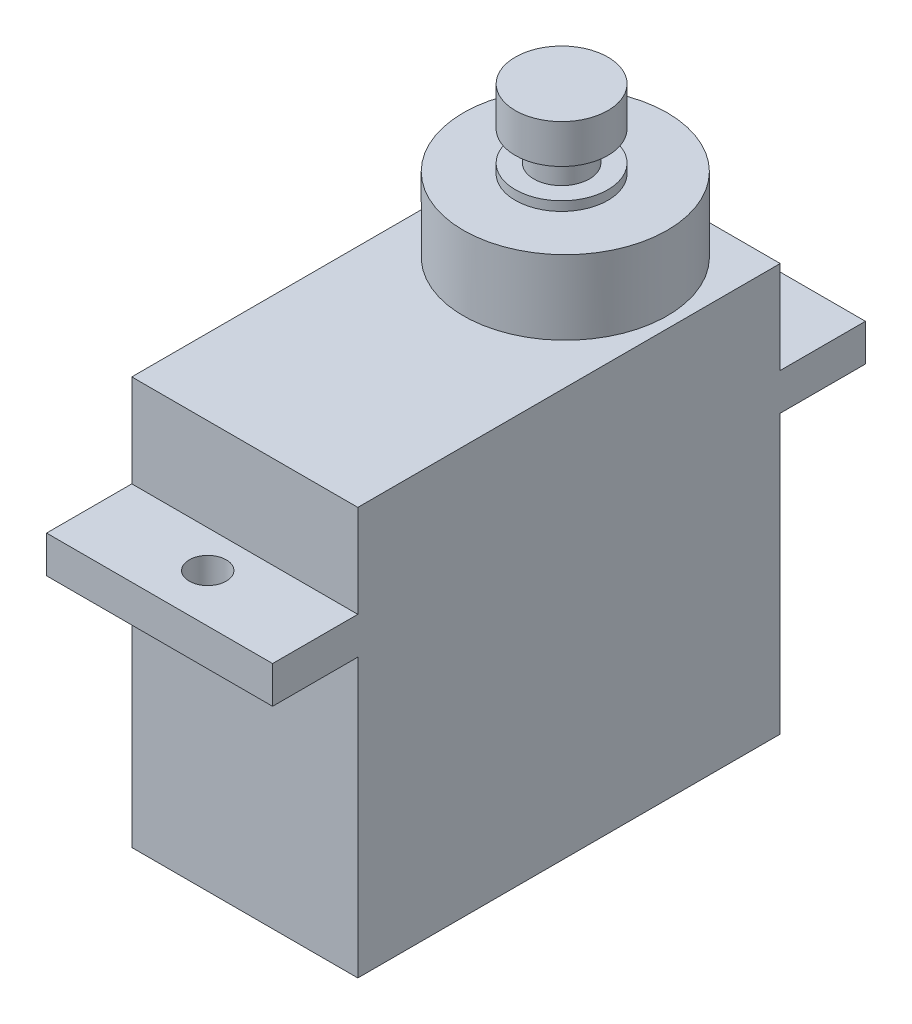
from build123d import *

# Parameters (mm, degrees)
SKETCH2_W           = 12.2
SKETCH2_H           = 22.8
BOSS_EXTRUDE1_DEPTH = 22
SKETCH3_W           = 12.2
SKETCH3_H           = 4.6
SKETCH3_R           = 1
BOSS_EXTRUDE2_DEPTH = 2
SKETCH4_R           = 5.5
BOSS_EXTRUDE3_DEPTH = 4
SKETCH5_R           = 2.5
BOSS_EXTRUDE4_DEPTH = 4.2
SKETCH6_W           = 1
SKETCH6_H           = 1.6


with BuildPart() as part:
    # Sketch2 → Boss-Extrude1 (new body)
    with BuildSketch(Plane(origin=(0, 0, 0), x_dir=(1, 0, 0), z_dir=(0, 1, 0))):
        Rectangle(SKETCH2_W, SKETCH2_H)
    extrude(amount=BOSS_EXTRUDE1_DEPTH)

    # Sketch3 → Boss-Extrude2 (add)
    with BuildSketch(Plane(origin=(0, 15, 0), x_dir=(1, 0, 0), z_dir=(0, 1, 0))):
        with Locations((0, 13.7)):
            Rectangle(SKETCH3_W, SKETCH3_H)
        with Locations((0, 13.4)):
            Circle(SKETCH3_R, mode=Mode.SUBTRACT)
        with Locations((0, -13.7)):
            Rectangle(SKETCH3_W, SKETCH3_H)
        with Locations((0, -13.4)):
            Circle(SKETCH3_R, mode=Mode.SUBTRACT)
    extrude(amount=BOSS_EXTRUDE2_DEPTH)

    # Sketch4 → Boss-Extrude3 (add)
    with BuildSketch(Plane(origin=(0, 22, 0), x_dir=(1, 0, 0), z_dir=(0, 1, 0))):
        with Locations((0, 5.9)):
            Circle(SKETCH4_R)
    extrude(amount=BOSS_EXTRUDE3_DEPTH)

    # Sketch5 → Boss-Extrude4 (add)
    with BuildSketch(Plane(origin=(0, 26, 0), x_dir=(1, 0, 0), z_dir=(0, 1, 0))):
        with Locations((0, 5.7)):
            Circle(SKETCH5_R)
    extrude(amount=BOSS_EXTRUDE4_DEPTH)

    # Sketch6 → Cut-Revolve1 (revolve, cut)
    with BuildSketch(Plane(origin=(0, 0, 0), x_dir=(0, 0, -1), z_dir=(1, 0, 0))):
        with Locations((7.7, 27.3)):
            Rectangle(SKETCH6_W, SKETCH6_H)
    revolve(axis=Axis((0, 30.2, -5.7), (0, -1, 0)), mode=Mode.SUBTRACT)


solid = part.part
